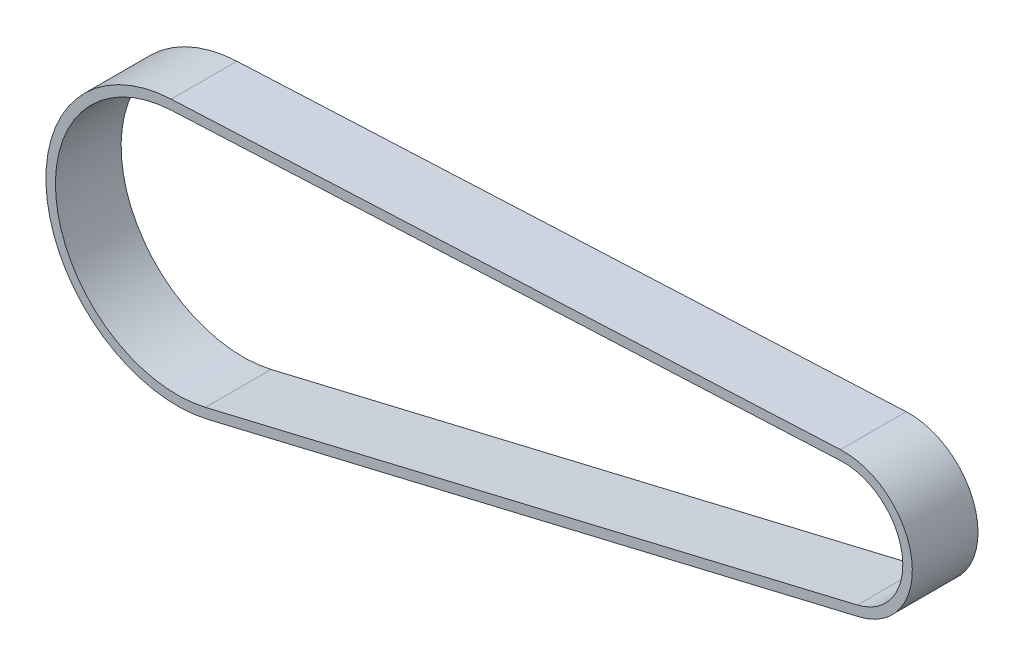
from build123d import *

# Parameters (mm, degrees)
EXTRUDE_THIN1_DEPTH = 6.9


with BuildPart() as part:
    # Sketch2 → Extrude-Thin1 (new body)
    with BuildSketch(Plane.XY):
        with BuildLine():
            Line((-101.293047192, 3.935094871), (-30.986990981, 7.205398561))
            ThreePointArc((-30.986990981, 7.205398561), (-23.509009794, 1.005096854), (-28.985542936, -7.018090084))
            Line((-28.985542936, -7.018090084), (-97.463952805, -23.276743407))
            ThreePointArc((-97.463952805, -23.276743407), (-114.317202558, -11.772913128), (-101.293047192, 3.935094871))
        make_face()
        with BuildLine():
            Line((-101.246582183, 2.936174953), (-30.940525973, 6.206478643))
            ThreePointArc((-30.940525973, 6.206478643), (-24.499254177, 0.865755323), (-29.216548536, -6.045137663))
            Line((-29.216548536, -6.045137663), (-97.694958405, -22.303790986))
            ThreePointArc((-97.694958405, -22.303790986), (-113.326958176, -11.633571597), (-101.246582183, 2.936174953))
        make_face(mode=Mode.SUBTRACT)
    extrude(amount=EXTRUDE_THIN1_DEPTH)


solid = part.part
